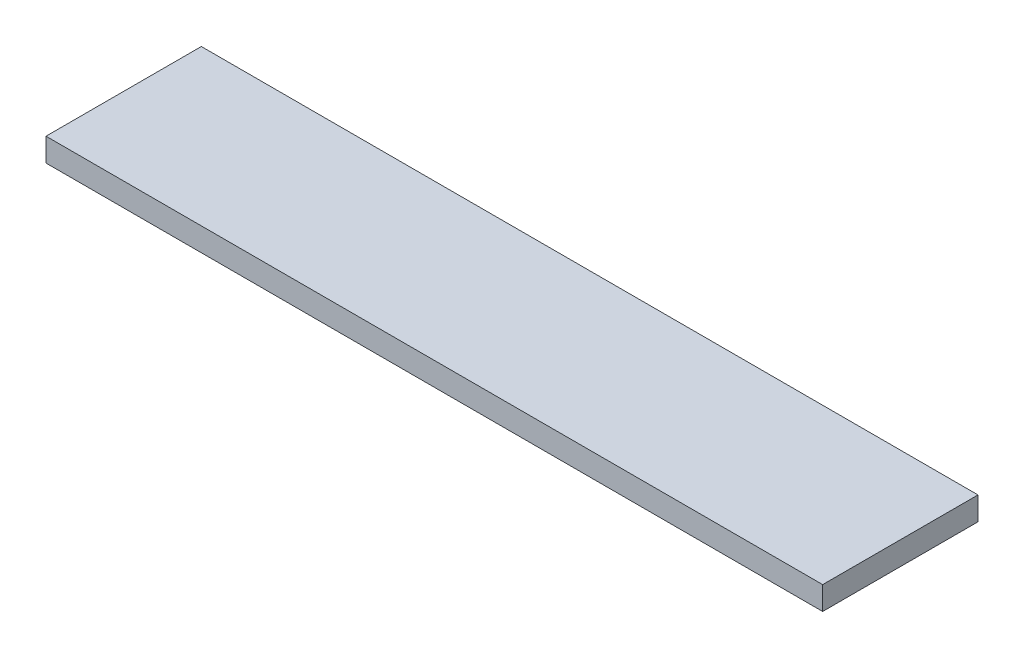
from build123d import *

# Parameters (mm, degrees)
SKETCH_1_W      = 20
SKETCH_1_H      = 3
EXTRUDE_1_DEPTH = 100


with BuildPart() as part:
    # Эскиз1 → Бобышка-Вытянуть1 (new body)
    with BuildSketch(Plane(origin=(0, 0, 0), x_dir=(0, 0, -1), z_dir=(1, 0, 0))):
        with Locations((10, 1.5)):
            Rectangle(SKETCH_1_W, SKETCH_1_H)
    extrude(amount=EXTRUDE_1_DEPTH)


solid = part.part
